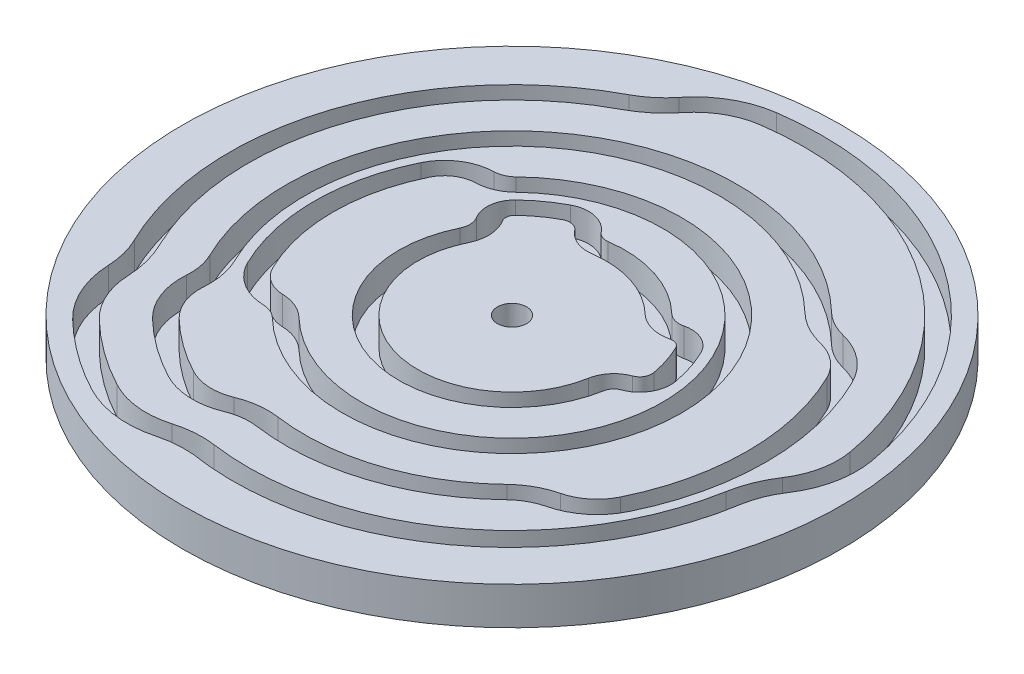
from build123d import *

# Parameters (mm, degrees)
EXTRUDE_1_DEPTH     = 3
EXTRUDE_1_2_DEPTH   = 3
EXTRUDE_1_3_DEPTH   = 3
EXTRUDE_1_4_DEPTH   = 3
SKETCH_1_R          = 35
EXTRUDE_1_5_DEPTH   = 3
SKETCH_3_R          = 35
EXTRUDE_2_DEPTH     = 1
SKETCH_4_R          = 1.55
CUT_EXTRUDE_1_DEPTH = 5


with BuildPart() as part:
    # 草图1 → 凸台-拉伸1 (new body)
    with BuildSketch(Plane(origin=(0, 0, 0), x_dir=(1, 0, 0), z_dir=(0, 1, 0))):
        with BuildLine():
            ThreePointArc((-8.987940463, 4.383711468), (-8.595708593, 6.301111944), (-9.178240759, 8.169514123))
            ThreePointArc((-9.178240759, 8.169514123), (-9.312956952, 8.786525533), (-9.030558816, 9.351417404))
            ThreePointArc((-9.030558816, 9.351417404), (-7.64120828, 10.517220927), (-6.103130316, 11.478318707))
            ThreePointArc((-6.103130316, 11.478318707), (-5.224804474, 11.603054959), (-4.470435457, 11.136211511))
            ThreePointArc((-4.470435457, 11.136211511), (-3.095389379, 10.109363067), (-1.39173101, 9.902680687))
            ThreePointArc((-1.39173101, 9.902680687), (3.090169944, 9.510565163), (6.946583705, 7.193398003))
            ThreePointArc((6.946583705, 7.193398003), (8.648933609, 6.227853996), (10.605902015, 6.204506982))
            ThreePointArc((10.605902015, 6.204506982), (11.23434433, 6.141962683), (11.684322602, 5.698824908))
            ThreePointArc((11.684322602, 5.698824908), (12.363734712, 4.017220927), (12.802500789, 2.25742631))
            ThreePointArc((12.802500789, 2.25742631), (12.649714402, 1.383543172), (11.972607053, 0.810358162))
            ThreePointArc((11.972607053, 0.810358162), (10.571103543, -0.180074751), (9.84807753, -1.736481777))
            ThreePointArc((9.84807753, -1.736481777), (-3.090169944, -9.510565163), (-8.987940463, 4.383711468))
        make_face()
    extrude(amount=EXTRUDE_1_DEPTH)



with BuildPart() as body_2:
    # 草图1 → Extrude 1 2 (new body)
    with BuildSketch(Plane(origin=(0, 0, 0), x_dir=(1, 0, 0), z_dir=(0, 1, 0))):
        with BuildLine():
            ThreePointArc((-11.114533927, -11.509436805), (-12.492455263, -10.599830784), (-14.105693288, -10.248386061))
            ThreePointArc((-14.105693288, -10.248386061), (-15.858793025, -9.702695478), (-17.07708688, -8.329051789))
            ThreePointArc((-17.07708688, -8.329051789), (-19, 0), (-17.07708688, 8.329051789))
            ThreePointArc((-17.07708688, 8.329051789), (-15.858793025, 9.702695478), (-14.105693288, 10.248386061))
            ThreePointArc((-14.105693288, 10.248386061), (-12.492455263, 10.599830784), (-11.114533927, 11.509436805))
            ThreePointArc((-11.114533927, 11.509436805), (16, 0), (-11.114533927, -11.509436805))
        make_face()
        with BuildLine():
            ThreePointArc((-10.785528556, 5.260453761), (-3.708203932, -11.412678196), (11.817693036, -2.083778132))
            ThreePointArc((11.817693036, -2.083778132), (12.10690446, -1.461213129), (12.667507838, -1.065038569))
            ThreePointArc((12.667507838, -1.065038569), (14.384650397, 0.388557195), (14.772116295, 2.604722665))
            ThreePointArc((14.772116295, 2.604722665), (14.265847744, 4.635254916), (13.481910694, 6.575567202))
            ThreePointArc((13.481910694, 6.575567202), (12.083449441, 7.952769275), (10.130350184, 8.147147056))
            ThreePointArc((10.130350184, 8.147147056), (9.17069564, 8.158595921), (8.335900446, 8.632077604))
            ThreePointArc((8.335900446, 8.632077604), (3.708203932, 11.412678196), (-1.670077212, 11.883216825))
            ThreePointArc((-1.670077212, 11.883216825), (-2.351542959, 11.965890068), (-2.901563328, 12.376630892))
            ThreePointArc((-2.901563328, 12.376630892), (-4.814641283, 13.560544718), (-7.042073442, 13.244213893))
            ThreePointArc((-7.042073442, 13.244213893), (-8.816778784, 12.135254916), (-10.419875557, 10.790097005))
            ThreePointArc((-10.419875557, 10.790097005), (-11.297524269, 9.034502472), (-10.878847662, 7.116928659))
            ThreePointArc((-10.878847662, 7.116928659), (-10.593186617, 6.200705058), (-10.785528556, 5.260453761))
        make_face(mode=Mode.SUBTRACT)
    extrude(amount=EXTRUDE_1_2_DEPTH)


with BuildPart() as body_3:
    # 草图1 → Extrude 1 3 (new body)
    with BuildSketch(Plane(origin=(0, 0, 0), x_dir=(1, 0, 0), z_dir=(0, 1, 0))):
        with BuildLine():
            ThreePointArc((18.937750033, -13.8084093), (21.021041042, -12.777130739), (22.469851157, -10.95927867))
            ThreePointArc((22.469851157, -10.95927867), (25, 0), (22.469851157, 10.95927867))
            ThreePointArc((22.469851157, 10.95927867), (21.021041042, 12.777130739), (18.937750033, 13.8084093))
            ThreePointArc((18.937750033, 13.8084093), (16.976365134, 14.574561246), (15.28248415, 15.825475607))
            ThreePointArc((15.28248415, 15.825475607), (-12.93127555, 17.798373876), (-19.773469019, -9.644165229))
            ThreePointArc((-19.773469019, -9.644165229), (-19.107216775, -11.641695573), (-18.98466424, -13.743837434))
            ThreePointArc((-18.98466424, -13.743837434), (-18.647632371, -16.043847525), (-17.366459261, -17.983495008))
            ThreePointArc((-17.366459261, -17.983495008), (-14.694631307, -20.225424859), (-11.73678907, -22.073689821))
            ThreePointArc((-11.73678907, -22.073689821), (-9.496170427, -22.69277382), (-7.204582268, -22.302567971))
            ThreePointArc((-7.204582268, -22.302567971), (-5.167455737, -21.769524797), (-3.061808221, -21.785897512))
            ThreePointArc((-3.061808221, -21.785897512), (6.798373876, -20.923243358), (15.28248415, -15.825475607))
            ThreePointArc((15.28248415, -15.825475607), (16.976365134, -14.574561246), (18.937750033, -13.8084093))
        make_face()
        with BuildLine():
            ThreePointArc((-12.503850668, -12.948116406), (-13.269414492, -12.44274542), (-14.165718687, -12.247485096))
            ThreePointArc((-14.165718687, -12.247485096), (-16.943967267, -11.382694545), (-18.874674972, -9.205794083))
            ThreePointArc((-18.874674972, -9.205794083), (-21, 0), (-18.874674972, 9.205794083))
            ThreePointArc((-18.874674972, 9.205794083), (-16.943967267, 11.382694545), (-14.165718687, 12.247485096))
            ThreePointArc((-14.165718687, 12.247485096), (-13.269414492, 12.44274542), (-12.503850668, 12.948116406))
            ThreePointArc((-12.503850668, 12.948116406), (18, 0), (-12.503850668, -12.948116406))
        make_face(mode=Mode.SUBTRACT)
    extrude(amount=EXTRUDE_1_3_DEPTH)


with BuildPart() as body_4:
    # 草图1 → Extrude 1 4 (new body)
    with BuildSketch(Plane(origin=(0, 0, 0), x_dir=(1, 0, 0), z_dir=(0, 1, 0))):
        with BuildLine():
            ThreePointArc((-4.31436613, 30.698310131), (18.221342821, 25.079526826), (30.529040343, 5.383093508))
            ThreePointArc((30.529040343, 5.383093508), (30.48111684, 2.285468824), (29.287623908, -0.573403325))
            ThreePointArc((29.287623908, -0.573403325), (28.210037241, -2.62947128), (27.574617084, -4.862148975))
            ThreePointArc((27.574617084, -4.862148975), (16.457987064, -22.652475842), (-3.896846827, -27.727505925))
            ThreePointArc((-3.896846827, -27.727505925), (-5.993969283, -27.657741779), (-8.058542774, -28.03234281))
            ThreePointArc((-8.058542774, -28.03234281), (-11.37088699, -28.338686756), (-14.553618446, -27.371375379))
            ThreePointArc((-14.553618446, -27.371375379), (-18.221342821, -25.079526826), (-21.534409484, -22.29953381))
            ThreePointArc((-21.534409484, -22.29953381), (-23.316376662, -19.765334071), (-24.031223485, -16.750940373))
            ThreePointArc((-24.031223485, -16.750940373), (-24.36796398, -14.454156905), (-25.166233296, -12.27439211))
            ThreePointArc((-25.166233296, -12.27439211), (-26.629582456, 8.652475843), (-13.145203758, 24.7225326))
            ThreePointArc((-13.145203758, 24.7225326), (-11.218156715, 26.016788431), (-9.595712481, 27.676994193))
            ThreePointArc((-9.595712481, 27.676994193), (-7.245573093, 29.695513501), (-4.31436613, 30.698310131))
        make_face()
        with BuildLine():
            ThreePointArc((24.26743925, -11.836020963), (27, 0), (24.26743925, 11.836020963))
            ThreePointArc((24.26743925, 11.836020963), (22.276722717, 14.333814244), (19.414206911, 15.750827598))
            ThreePointArc((19.414206911, 15.750827598), (17.942654929, 16.325642065), (16.671800891, 17.264155208))
            ThreePointArc((16.671800891, 17.264155208), (-14.106846055, 19.416407865), (-21.571057111, -10.520907523))
            ThreePointArc((-21.571057111, -10.520907523), (-21.071193566, -12.019578048), (-20.979247092, -13.596734588))
            ThreePointArc((-20.979247092, -13.596734588), (-20.516153338, -16.757030106), (-18.755776002, -19.422174609))
            ThreePointArc((-18.755776002, -19.422174609), (-15.870201812, -21.843458848), (-12.675732195, -23.839585007))
            ThreePointArc((-12.675732195, -23.839585007), (-9.597042635, -24.6902284), (-6.448319149, -24.15407171))
            ThreePointArc((-6.448319149, -24.15407171), (-4.919941122, -23.754149829), (-3.340154423, -23.76643365))
            ThreePointArc((-3.340154423, -23.76643365), (7.416407865, -22.825356391), (16.671800891, -17.264155208))
            ThreePointArc((16.671800891, -17.264155208), (17.942654929, -16.325642065), (19.414206911, -15.750827598))
            ThreePointArc((19.414206911, -15.750827598), (22.276722717, -14.333814244), (24.26743925, -11.836020963))
        make_face(mode=Mode.SUBTRACT)
    extrude(amount=EXTRUDE_1_4_DEPTH)


with BuildPart() as body_5:
    # 草图1 → Extrude 1 5 (new body)
    with BuildSketch(Plane(origin=(0, 0, 0), x_dir=(1, 0, 0), z_dir=(0, 1, 0))):
        Circle(SKETCH_1_R)
        with BuildLine():
            ThreePointArc((-4.592712332, 32.678846268), (-8.238694275, 31.431517625), (-11.161915282, 28.920782272))
            ThreePointArc((-11.161915282, 28.920782272), (-12.497644107, 27.553965069), (-14.084146884, 26.488427786))
            ThreePointArc((-14.084146884, 26.488427786), (-28.531695489, 9.270509831), (-26.963821389, -13.151134404))
            ThreePointArc((-26.963821389, -13.151134404), (-26.306620782, -14.945695108), (-26.029388457, -16.836595159))
            ThreePointArc((-26.029388457, -16.836595159), (-25.140226197, -20.586048925), (-22.923726225, -23.738213411))
            ThreePointArc((-22.923726225, -23.738213411), (-19.396913326, -26.697560814), (-15.492561572, -29.137270564))
            ThreePointArc((-15.492561572, -29.137270564), (-11.698213434, -30.314961384), (-7.736329089, -30.019147427))
            ThreePointArc((-7.736329089, -30.019147427), (-5.969810062, -29.709434307), (-4.176359771, -29.716343862))
            ThreePointArc((-4.176359771, -29.716343862), (17.759481282, -24.44665794), (29.54423259, -5.20944533))
            ThreePointArc((29.54423259, -5.20944533), (30.067362447, -3.371322398), (30.954519948, -1.678599051))
            ThreePointArc((30.954519948, -1.678599051), (32.439046197, 1.87740923), (32.498655849, 5.730389863))
            ThreePointArc((32.498655849, 5.730389863), (19.396913326, 26.697560814), (-4.592712332, 32.678846268))
        make_face(mode=Mode.SUBTRACT)
    extrude(amount=EXTRUDE_1_5_DEPTH)


with BuildPart() as part_1:
    add(part.part)

    add(body_2.part)  # 凸台-拉伸2 merges body 2

    add(body_3.part)  # 凸台-拉伸2 merges body 3

    add(body_4.part)  # 凸台-拉伸2 merges body 4

    add(body_5.part)  # 凸台-拉伸2 merges body 5
    # 草图3 → 凸台-拉伸2 (add)
    with BuildSketch(Plane.XZ):
        Circle(SKETCH_3_R)
    extrude(amount=EXTRUDE_2_DEPTH)

    # 草图4 → 切除-拉伸1 (cut, through all)
    with BuildSketch(Plane(origin=(0, 3, 0), x_dir=(1, 0, 0), z_dir=(0, 1, 0))):
        Circle(SKETCH_4_R)
    extrude(amount=-CUT_EXTRUDE_1_DEPTH, mode=Mode.SUBTRACT)


solid = part_1.part
